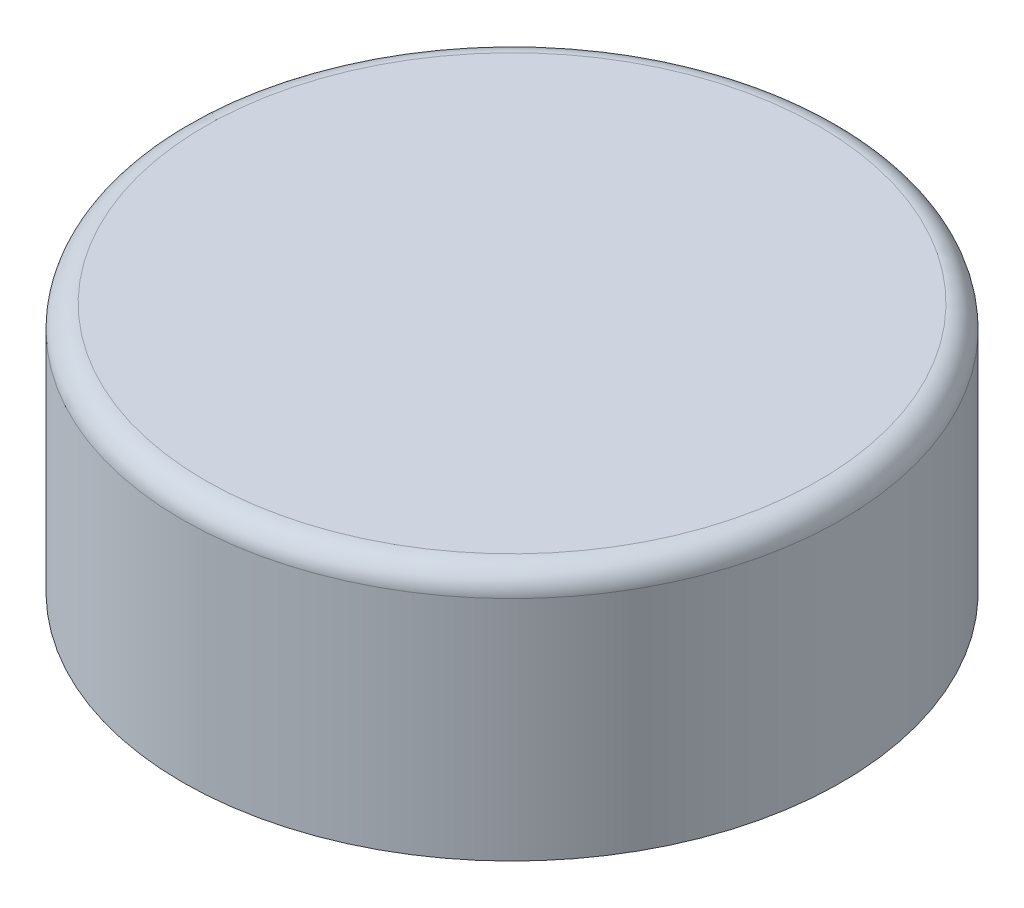
from build123d import *

# Parameters (mm, degrees)
SKETCH1_R           = 1.45
BOSS_EXTRUDE1_DEPTH = 1.1
FILLET1_R           = 0.1


with BuildPart() as part:
    # Sketch1 → Boss-Extrude1 (new body)
    with BuildSketch(Plane(origin=(0, 0, 0), x_dir=(1, 0, 0), z_dir=(0, 1, 0))):
        Circle(SKETCH1_R)
    extrude(amount=BOSS_EXTRUDE1_DEPTH)

    # Fillet1
    fillet1_edges = [part.edges().sort_by_distance(p)[0] for p in [
        (-1.45, 1.1, 0),
    ]]
    fillet(fillet1_edges, radius=FILLET1_R)


solid = part.part
